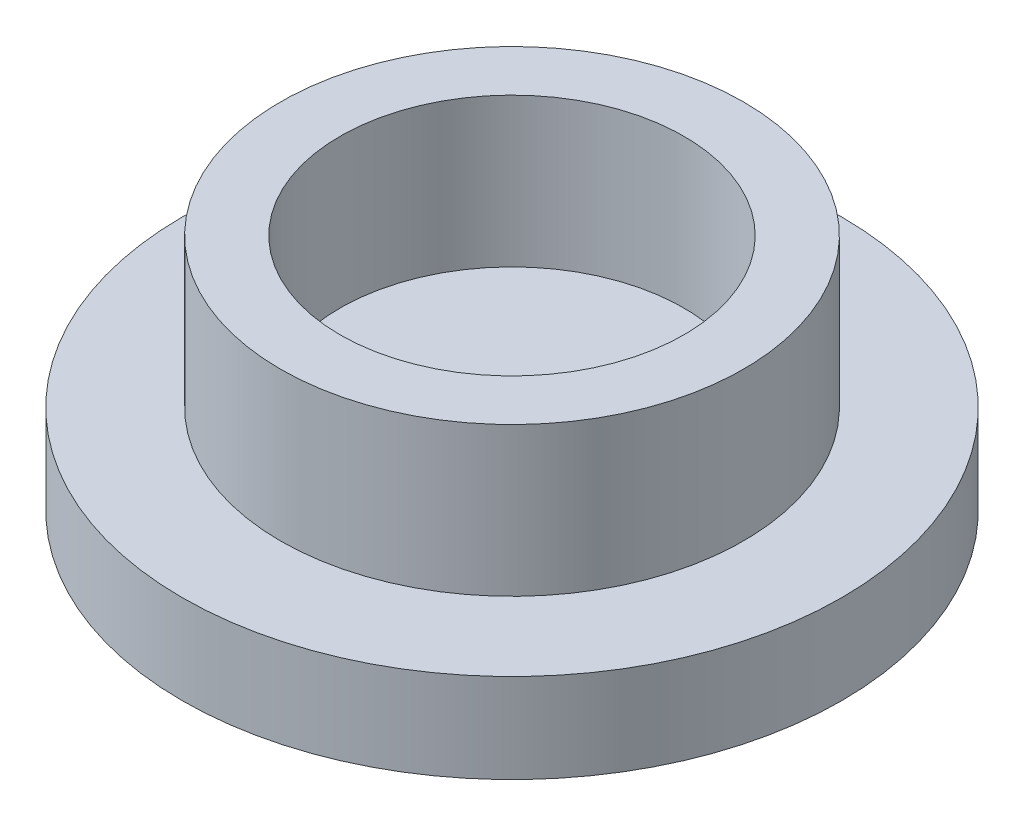
from build123d import *

# Parameters (mm, degrees)
SKETCH1_R           = 11.08
BOSS_EXTRUDE1_DEPTH = 3
SKETCH2_R           = 7.78
SKETCH2_R_2         = 5.78
BOSS_EXTRUDE2_DEPTH = 5


with BuildPart() as part:
    # Sketch1 → Boss-Extrude1 (new body)
    with BuildSketch(Plane(origin=(0, 0, 0), x_dir=(1, 0, 0), z_dir=(0, 1, 0))):
        Circle(SKETCH1_R)
    extrude(amount=BOSS_EXTRUDE1_DEPTH)

    # Sketch2 → Boss-Extrude2 (add)
    with BuildSketch(Plane(origin=(0, 3, 0), x_dir=(1, 0, 0), z_dir=(0, 1, 0))):
        Circle(SKETCH2_R)
        Circle(SKETCH2_R_2, mode=Mode.SUBTRACT)
    extrude(amount=BOSS_EXTRUDE2_DEPTH)


solid = part.part
